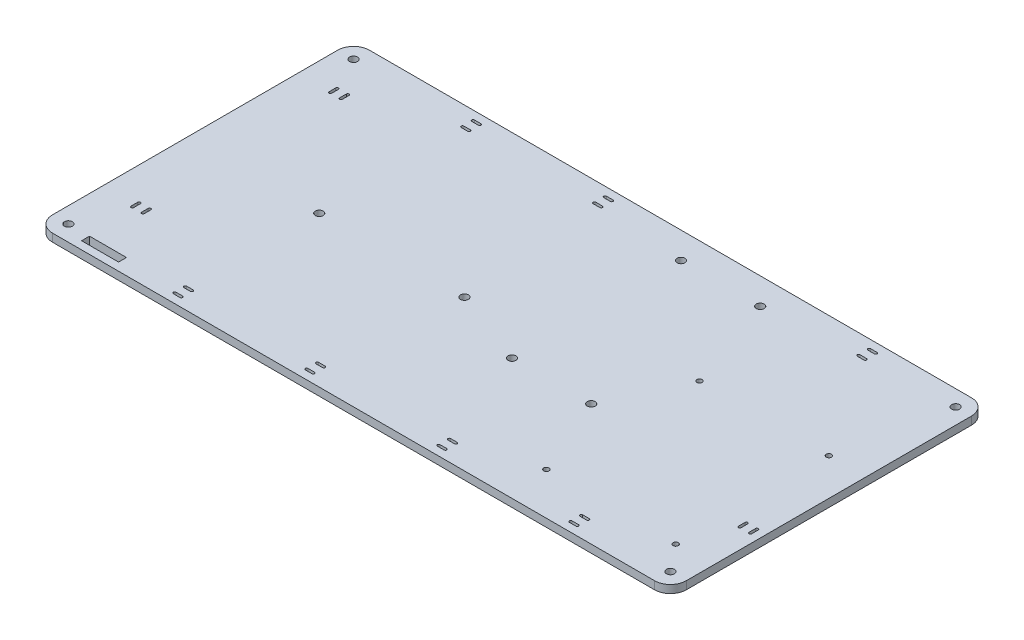
from build123d import *

# Parameters (mm, degrees)
SKETCH1_W           = 240
SKETCH1_H           = 120
SKETCH1_W_2         = 14
SKETCH1_H_2         = 3
BOSS_EXTRUDE1_DEPTH = 3
FILLET1_R           = 6
SKETCH2_R           = 1.5
CUT_EXTRUDE2_DEPTH  = 4
SKETCH3_R           = 1.5
CUT_EXTRUDE3_DEPTH  = 4
SKETCH4_R           = 1.5
CUT_EXTRUDE4_DEPTH  = 4
SKETCH5_R           = 1
CUT_EXTRUDE5_DEPTH  = 4
CUT_EXTRUDE6_DEPTH  = 4


with BuildPart() as part:
    # Sketch1 → Boss-Extrude1 (new body)
    with BuildSketch(Plane(origin=(0, 0, 0), x_dir=(1, 0, 0), z_dir=(0, 1, 0))):
        Rectangle(SKETCH1_W, SKETCH1_H)
        with Locations((-99, -55.5)):
            Rectangle(SKETCH1_W_2, SKETCH1_H_2, mode=Mode.SUBTRACT)
    extrude(amount=BOSS_EXTRUDE1_DEPTH)

    # Fillet1
    fillet1_edges = [part.edges().sort_by_distance(p)[0] for p in [
        (-120, 1.5, -60),
        (120, 1.5, -60),
        (120, 1.5, 60),
        (-120, 1.5, 60),
    ]]
    fillet(fillet1_edges, radius=FILLET1_R)

    # Sketch2 → Cut-Extrude2 (cut, through all)
    with BuildSketch(Plane(origin=(0, 0, 0), x_dir=(1, 0, 0), z_dir=(0, 1, 0))):
        with Locations((-114, 54)):
            Circle(SKETCH2_R)
        with Locations((114, 54)):
            Circle(SKETCH2_R)
        with Locations((-114, -54)):
            Circle(SKETCH2_R)
        with Locations((114, -54)):
            Circle(SKETCH2_R)
    extrude(amount=CUT_EXTRUDE2_DEPTH, mode=Mode.SUBTRACT)

    # Sketch3 → Cut-Extrude3 (cut, through all)
    with BuildSketch(Plane(origin=(0, 3, 0), x_dir=(1, 0, 0), z_dir=(0, 1, 0))):
        with Locations((-70, -3)):
            Circle(SKETCH3_R)
        with Locations((-15, -3)):
            Circle(SKETCH3_R)
    extrude(amount=-CUT_EXTRUDE3_DEPTH, mode=Mode.SUBTRACT)

    # Sketch4 → Cut-Extrude4 (cut, through all)
    with BuildSketch(Plane(origin=(0, 3, 0), x_dir=(1, 0, 0), z_dir=(0, 1, 0))):
        with Locations((44, 50)):
            Circle(SKETCH4_R)
        with Locations((14, 50)):
            Circle(SKETCH4_R)
        with Locations((44, -14)):
            Circle(SKETCH4_R)
        with Locations((14, -14)):
            Circle(SKETCH4_R)
    extrude(amount=-CUT_EXTRUDE4_DEPTH, mode=Mode.SUBTRACT)

    # Sketch5 → Cut-Extrude5 (cut, through all)
    with BuildSketch(Plane(origin=(0, 3, 0), x_dir=(1, 0, 0), z_dir=(0, 1, 0))):
        with Locations((106, 14)):
            Circle(SKETCH5_R)
        with Locations((106, -44)):
            Circle(SKETCH5_R)
        with Locations((57, -44)):
            Circle(SKETCH5_R)
        with Locations((57, 14)):
            Circle(SKETCH5_R)
    extrude(amount=-CUT_EXTRUDE5_DEPTH, mode=Mode.SUBTRACT)

    # Sketch7 → Cut-Extrude6 (cut, through all)
    with BuildSketch(Plane(origin=(0, 3, 0), x_dir=(1, 0, 0), z_dir=(0, 1, 0))):
        with BuildLine():
            Line((117, -23.75), (117, -26.25))
            ThreePointArc((117, -26.25), (116.5, -26.75), (116, -26.25))
            Line((116, -26.25), (116, -23.75))
            ThreePointArc((116, -23.75), (116.5, -23.25), (117, -23.75))
        make_face()
        with BuildLine():
            Line((113, -23.75), (113, -26.25))
            ThreePointArc((113, -26.25), (112.5, -26.75), (112, -26.25))
            Line((112, -26.25), (112, -23.75))
            ThreePointArc((112, -23.75), (112.5, -23.25), (113, -23.75))
        make_face()
        with BuildLine():
            Line((81.25, -53), (78.75, -53))
            ThreePointArc((78.75, -53), (78.25, -52.5), (78.75, -52))
            Line((78.75, -52), (81.25, -52))
            ThreePointArc((81.25, -52), (81.75, -52.5), (81.25, -53))
        make_face()
        with BuildLine():
            Line((81.25, -57), (78.75, -57))
            ThreePointArc((78.75, -57), (78.25, -56.5), (78.75, -56))
            Line((78.75, -56), (81.25, -56))
            ThreePointArc((81.25, -56), (81.75, -56.5), (81.25, -57))
        make_face()
        with BuildLine():
            Line((31.25, -53), (28.75, -53))
            ThreePointArc((28.75, -53), (28.25, -52.5), (28.75, -52))
            Line((28.75, -52), (31.25, -52))
            ThreePointArc((31.25, -52), (31.75, -52.5), (31.25, -53))
        make_face()
        with BuildLine():
            Line((31.25, -57), (28.75, -57))
            ThreePointArc((28.75, -57), (28.25, -56.5), (28.75, -56))
            Line((28.75, -56), (31.25, -56))
            ThreePointArc((31.25, -56), (31.75, -56.5), (31.25, -57))
        make_face()
        with BuildLine():
            Line((-18.75, -53), (-21.25, -53))
            ThreePointArc((-21.25, -53), (-21.75, -52.5), (-21.25, -52))
            Line((-21.25, -52), (-18.75, -52))
            ThreePointArc((-18.75, -52), (-18.25, -52.5), (-18.75, -53))
        make_face()
        with BuildLine():
            Line((-18.75, -57), (-21.25, -57))
            ThreePointArc((-21.25, -57), (-21.75, -56.5), (-21.25, -56))
            Line((-21.25, -56), (-18.75, -56))
            ThreePointArc((-18.75, -56), (-18.25, -56.5), (-18.75, -57))
        make_face()
        with BuildLine():
            Line((-68.75, -53), (-71.25, -53))
            ThreePointArc((-71.25, -53), (-71.75, -52.5), (-71.25, -52))
            Line((-71.25, -52), (-68.75, -52))
            ThreePointArc((-68.75, -52), (-68.25, -52.5), (-68.75, -53))
        make_face()
        with BuildLine():
            Line((-68.75, -57), (-71.25, -57))
            ThreePointArc((-71.25, -57), (-71.75, -56.5), (-71.25, -56))
            Line((-71.25, -56), (-68.75, -56))
            ThreePointArc((-68.75, -56), (-68.25, -56.5), (-68.75, -57))
        make_face()
        with BuildLine():
            Line((81.25, 57), (78.75, 57))
            ThreePointArc((78.75, 57), (78.25, 56.5), (78.75, 56))
            Line((78.75, 56), (81.25, 56))
            ThreePointArc((81.25, 56), (81.75, 56.5), (81.25, 57))
        make_face()
        with BuildLine():
            Line((81.25, 53), (78.75, 53))
            ThreePointArc((78.75, 53), (78.25, 52.5), (78.75, 52))
            Line((78.75, 52), (81.25, 52))
            ThreePointArc((81.25, 52), (81.75, 52.5), (81.25, 53))
        make_face()
        with BuildLine():
            Line((-18.75, 57), (-21.25, 57))
            ThreePointArc((-21.25, 57), (-21.75, 56.5), (-21.25, 56))
            Line((-21.25, 56), (-18.75, 56))
            ThreePointArc((-18.75, 56), (-18.25, 56.5), (-18.75, 57))
        make_face()
        with BuildLine():
            Line((-18.75, 53), (-21.25, 53))
            ThreePointArc((-21.25, 53), (-21.75, 52.5), (-21.25, 52))
            Line((-21.25, 52), (-18.75, 52))
            ThreePointArc((-18.75, 52), (-18.25, 52.5), (-18.75, 53))
        make_face()
        with BuildLine():
            Line((-68.75, 57), (-71.25, 57))
            ThreePointArc((-71.25, 57), (-71.75, 56.5), (-71.25, 56))
            Line((-71.25, 56), (-68.75, 56))
            ThreePointArc((-68.75, 56), (-68.25, 56.5), (-68.75, 57))
        make_face()
        with BuildLine():
            Line((-68.75, 53), (-71.25, 53))
            ThreePointArc((-71.25, 53), (-71.75, 52.5), (-71.25, 52))
            Line((-71.25, 52), (-68.75, 52))
            ThreePointArc((-68.75, 52), (-68.25, 52.5), (-68.75, 53))
        make_face()
        with BuildLine():
            Line((-103, -33.75), (-103, -36.25))
            ThreePointArc((-103, -36.25), (-103.5, -36.75), (-104, -36.25))
            Line((-104, -36.25), (-104, -33.75))
            ThreePointArc((-104, -33.75), (-103.5, -33.25), (-103, -33.75))
        make_face()
        with BuildLine():
            Line((-107, -33.75), (-107, -36.25))
            ThreePointArc((-107, -36.25), (-107.5, -36.75), (-108, -36.25))
            Line((-108, -36.25), (-108, -33.75))
            ThreePointArc((-108, -33.75), (-107.5, -33.25), (-107, -33.75))
        make_face()
        with BuildLine():
            Line((-103, 41.25), (-103, 38.75))
            ThreePointArc((-103, 38.75), (-103.5, 38.25), (-104, 38.75))
            Line((-104, 38.75), (-104, 41.25))
            ThreePointArc((-104, 41.25), (-103.5, 41.75), (-103, 41.25))
        make_face()
        with BuildLine():
            Line((-107, 41.25), (-107, 38.75))
            ThreePointArc((-107, 38.75), (-107.5, 38.25), (-108, 38.75))
            Line((-108, 38.75), (-108, 41.25))
            ThreePointArc((-108, 41.25), (-107.5, 41.75), (-107, 41.25))
        make_face()
    extrude(amount=-CUT_EXTRUDE6_DEPTH, mode=Mode.SUBTRACT)


solid = part.part
